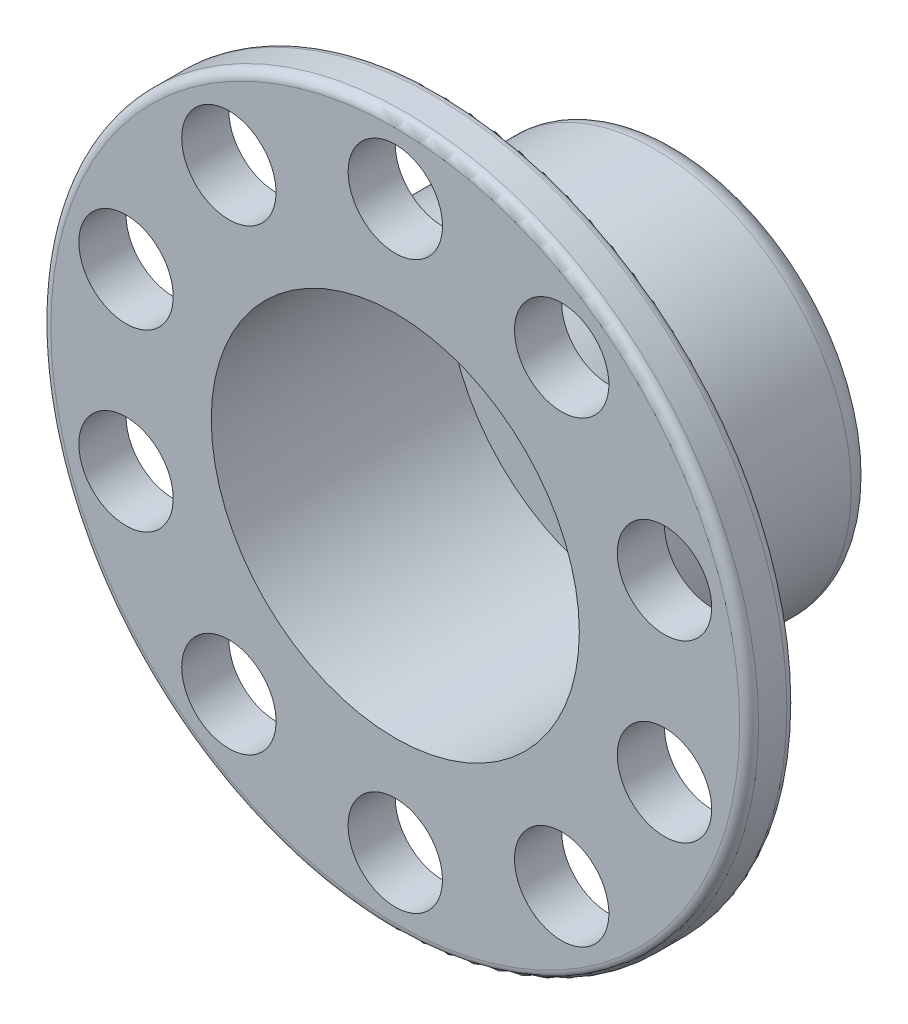
from build123d import *

# Parameters (mm, degrees)
SKETCH2_R           = 75
SKETCH2_R_2         = 40
EXTRUDE_THIN1_DEPTH = 10
SKETCH3_R           = 41.655
SKETCH3_R_2         = 39.005
EXTRUDE_THIN2_DEPTH = 60
SKETCH4_R           = 39.005
BOSS_EXTRUDE1_DEPTH = 10
SKETCH5_R           = 10
CUT_EXTRUDE1_DEPTH  = 11
FILLET1_R           = 5
FILLET2_R           = 2


with BuildPart() as part:
    # Sketch2 → Extrude-Thin1 (new body)
    with BuildSketch(Plane.XY):
        Circle(SKETCH2_R)
        Circle(SKETCH2_R_2, mode=Mode.SUBTRACT)
    extrude(amount=EXTRUDE_THIN1_DEPTH)

    # Sketch3 → Extrude-Thin2 (add)
    with BuildSketch(Plane.XY.offset(10)):
        Circle(SKETCH3_R)
        Circle(SKETCH3_R_2, mode=Mode.SUBTRACT)
    extrude(amount=-EXTRUDE_THIN2_DEPTH)

    # Sketch4 → Boss-Extrude1 (add)
    with BuildSketch(Plane(origin=(0, 0, -50), x_dir=(-1, 0, 0), z_dir=(0, 0, -1))):
        Circle(SKETCH4_R)
    extrude(amount=-BOSS_EXTRUDE1_DEPTH)

    # Sketch5 → Cut-Extrude1 (cut, through all)
    with BuildSketch(Plane(origin=(0, 0, 0), x_dir=(-1, 0, 0), z_dir=(0, 0, -1))):
        with Locations((0, 60)):
            Circle(SKETCH5_R)
        with Locations((35.267115138, 48.541019662)):
            Circle(SKETCH5_R)
        with Locations((57.063390978, 18.541019662)):
            Circle(SKETCH5_R)
        with Locations((57.063390978, -18.541019662)):
            Circle(SKETCH5_R)
        with Locations((35.267115138, -48.541019662)):
            Circle(SKETCH5_R)
        with Locations((0, -60)):
            Circle(SKETCH5_R)
        with Locations((-35.267115138, -48.541019662)):
            Circle(SKETCH5_R)
        with Locations((-57.063390978, -18.541019662)):
            Circle(SKETCH5_R)
        with Locations((-57.063390978, 18.541019662)):
            Circle(SKETCH5_R)
        with Locations((-35.267115138, 48.541019662)):
            Circle(SKETCH5_R)
    extrude(amount=-CUT_EXTRUDE1_DEPTH, mode=Mode.SUBTRACT)

    # Fillet1
    fillet1_edges = [part.edges().sort_by_distance(p)[0] for p in [
        (-41.655, 0, -50),
    ]]
    fillet(fillet1_edges, radius=FILLET1_R)

    # Fillet2
    fillet2_edges = [part.edges().sort_by_distance(p)[0] for p in [
        (-75, 0, 0),
        (-75, 0, 10),
    ]]
    fillet(fillet2_edges, radius=FILLET2_R)


solid = part.part
